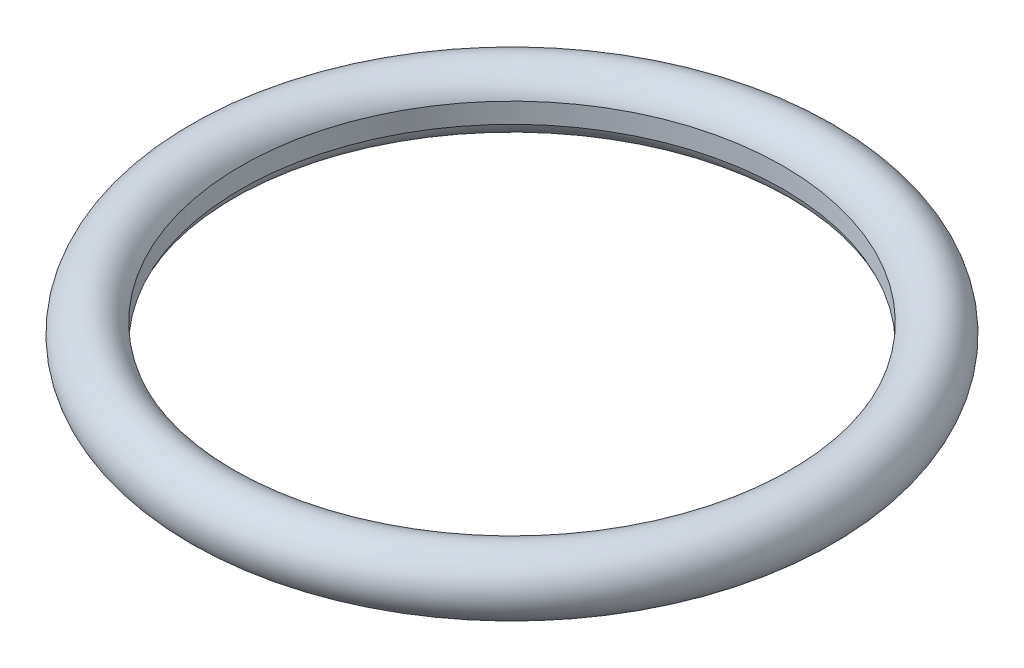
from build123d import *


with BuildPart() as part:
    # Sketch2 → Revolve1 (revolve)
    with BuildSketch(Plane.XY):
        with BuildLine():
            Line((-13.5, -0.5), (-13.5, 0.5))
            ThreePointArc((-13.5, 0.5), (-16.414213562, 0), (-13.5, -0.5))
        make_face()
    revolve(axis=Axis((0, 0, 0), (0, 1, 0)))


solid = part.part
